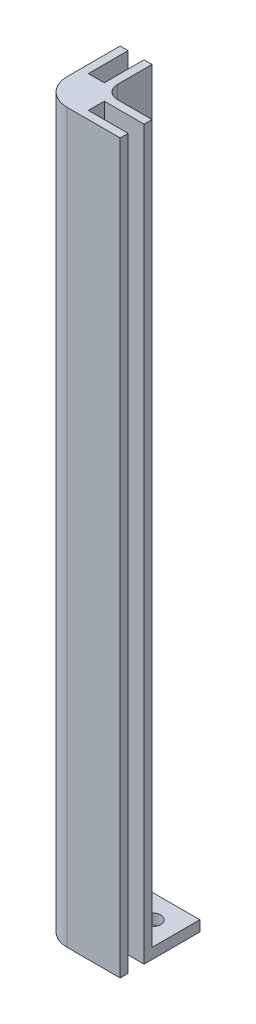
from build123d import *

# Parameters (mm, degrees)
BOSS_EXTRUDE1_DEPTH = 135
SKETCH6_R           = 1.6
BOSS_EXTRUDE2_DEPTH = 2
FILLET3_R           = 5
FILLET4_R           = 2.5


with BuildPart() as part:
    # Sketch4 → Boss-Extrude1 (new body)
    with BuildSketch(Plane(origin=(0, 0, 0), x_dir=(1, 0, 0), z_dir=(0, 1, 0))):
        Polygon((-7.5, -7.5), (7.5, -7.5), (7.5, -6), (0, -6), (0, -3), (7.5, -3), (7.5, -1.5), (-1.5, -1.5), (-1.5, 7.5), (-3, 7.5), (-3, 0), (-6, 0), (-6, 7.5), (-7.5, 7.5), align=None)
    extrude(amount=BOSS_EXTRUDE1_DEPTH)

    # Sketch6 → Boss-Extrude2 (add)
    with BuildSketch(Plane.XZ):
        Polygon((7.5, 7.5), (-7.5, 7.5), (-7.5, -7.5), (-6, -7.5), (-6, 0), (-3, 0), (-3, -7.5), (-1.5, -7.5), (7.5, -7.5), (7.5, 1.5), (7.5, 3), (0, 3), (0, 6), (7.5, 6), align=None)
        with Locations((3, -3)):
            Circle(SKETCH6_R, mode=Mode.SUBTRACT)
    extrude(amount=BOSS_EXTRUDE2_DEPTH)

    # Fillet3
    fillet3_edges = [part.edges().sort_by_distance(p)[0] for p in [
        (-7.5, 66.5, 7.5),
    ]]
    fillet(fillet3_edges, radius=FILLET3_R)

    # Fillet4
    fillet4_edges = [part.edges().sort_by_distance(p)[0] for p in [
        (-1.5, 67.5, 1.5),
    ]]
    fillet(fillet4_edges, radius=FILLET4_R)


solid = part.part
